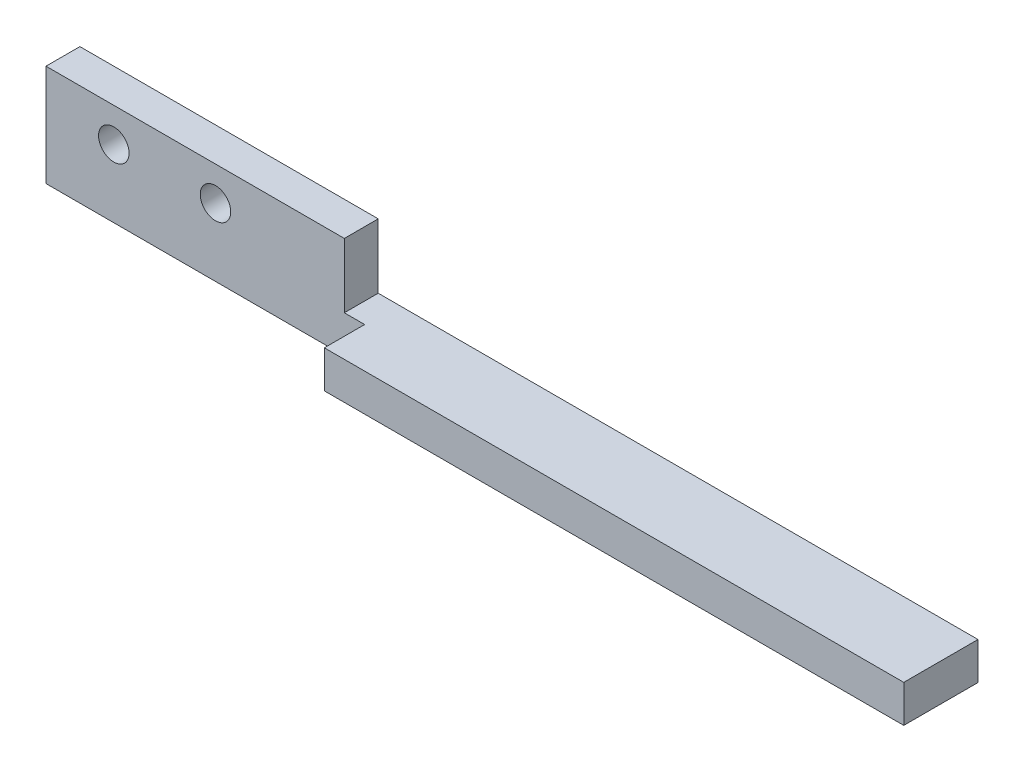
from build123d import *

# Parameters (mm, degrees)
SKETCH_1_W          = 100
SKETCH_1_H          = 25
EXTRUDE_1_DEPTH     = 5
SKETCH_2_W          = 53
SKETCH_2_H          = 5
EXTRUDE_2_DEPTH     = 5
SKETCH_5_W          = 56
SKETCH_5_H          = 5
CUT_EXTRUDE_1_DEPTH = 10
SKETCH_6_W          = 5
SKETCH_6_H          = 5
EXTRUDE_3_DEPTH     = 47
SKETCH_7_W          = 56
SKETCH_7_H          = 5
CUT_EXTRUDE_2_DEPTH = 14.5
SKETCH_8_W          = 53
SKETCH_8_H          = 5.5
EXTRUDE_4_DEPTH     = 5.95
SKETCH_9_W          = 10.95
SKETCH_9_H          = 5.5
EXTRUDE_5_DEPTH     = 32.46
SKETCH_11_W         = 44
SKETCH_11_H         = 5
CUT_EXTRUDE_3_DEPTH = 15
SKETCH_12_R         = 2.25
CUT_EXTRUDE_4_DEPTH = 15


with BuildPart() as part:
    # 草图1 → 凸台-拉伸1 (new body)
    with BuildSketch(Plane.XY):
        with Locations((50, 12.5)):
            Rectangle(SKETCH_1_W, SKETCH_1_H)
    extrude(amount=EXTRUDE_1_DEPTH)

    # 草图2 → 凸台-拉伸2 (add)
    with BuildSketch(Plane.XZ):
        with Locations((73.5, 2.5)):
            Rectangle(SKETCH_2_W, SKETCH_2_H)
    extrude(amount=EXTRUDE_2_DEPTH)

    # 草图5 → 切除-拉伸1 (cut)
    with BuildSketch(Plane(origin=(0, 25, 0), x_dir=(1, 0, 0), z_dir=(0, 1, 0))):
        with Locations((72, -2.5)):
            Rectangle(SKETCH_5_W, SKETCH_5_H)
    extrude(amount=-CUT_EXTRUDE_1_DEPTH, mode=Mode.SUBTRACT)

    # 草图6 → 凸台-拉伸3 (add)
    with BuildSketch(Plane.ZY.offset(-47)):
        with Locations((2.5, -2.5)):
            Rectangle(SKETCH_6_W, SKETCH_6_H)
    extrude(amount=EXTRUDE_3_DEPTH)

    # 草图7 → 切除-拉伸2 (cut)
    with BuildSketch(Plane(origin=(0, 15, 0), x_dir=(1, 0, 0), z_dir=(0, 1, 0))):
        with Locations((72, -2.5)):
            Rectangle(SKETCH_7_W, SKETCH_7_H)
    extrude(amount=-CUT_EXTRUDE_2_DEPTH, mode=Mode.SUBTRACT)

    # 草图8 → 凸台-拉伸4 (add)
    with BuildSketch(Plane.XY.offset(5)):
        with Locations((73.5, -2.25)):
            Rectangle(SKETCH_8_W, SKETCH_8_H)
    extrude(amount=EXTRUDE_4_DEPTH)

    # 草图9 → 凸台-拉伸5 (add)
    with BuildSketch(Plane(origin=(100, 0, 0), x_dir=(0, 0, -1), z_dir=(1, 0, 0))):
        with Locations((-5.475, -2.25)):
            Rectangle(SKETCH_9_W, SKETCH_9_H)
    extrude(amount=EXTRUDE_5_DEPTH)

    # 草图11 → 切除-拉伸3 (cut)
    with BuildSketch(Plane(origin=(0, 25, 0), x_dir=(1, 0, 0), z_dir=(0, 1, 0))):
        with Locations((22, -2.5)):
            Rectangle(SKETCH_11_W, SKETCH_11_H)
    extrude(amount=-CUT_EXTRUDE_3_DEPTH, mode=Mode.SUBTRACT)

    # 草图12 → 切除-拉伸4 (cut)
    with BuildSketch(Plane(origin=(0, 0, 0), x_dir=(-1, 0, 0), z_dir=(0, 0, -1))):
        with Locations((-10, 5)):
            Circle(SKETCH_12_R)
        with Locations((-25, 5)):
            Circle(SKETCH_12_R)
    extrude(amount=-CUT_EXTRUDE_4_DEPTH, mode=Mode.SUBTRACT)


solid = part.part
